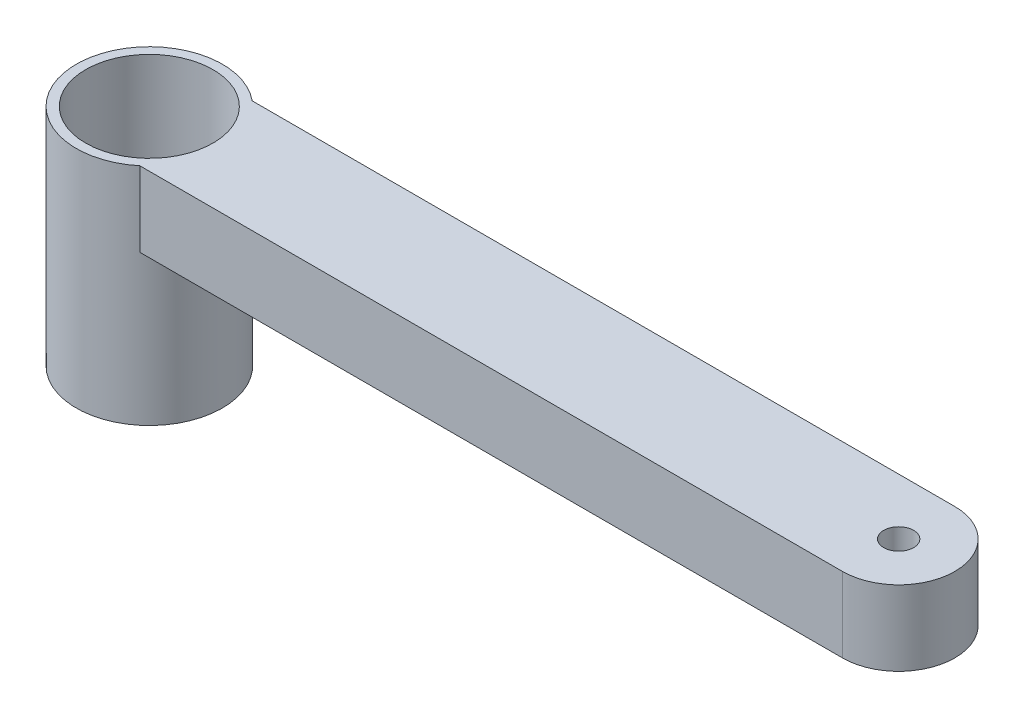
from build123d import *

# Parameters (mm, degrees)
SKETCH2_R           = 2.5
SKETCH2_R_2         = 2
BOSS_EXTRUDE1_DEPTH = 10
SKETCH3_R           = 9.75
BOSS_EXTRUDE2_DEPTH = 30
CUT_EXTRUDE1_REACH  = 32
SKETCH4_R           = 8.5


with BuildPart() as part:
    # Sketch2 → Boss-Extrude1 (new body)
    with BuildSketch(Plane(origin=(0, 0, 0), x_dir=(1, 0, 0), z_dir=(0, 1, 0))):
        with BuildLine():
            Line((0, 7.5), (100, 7.5))
            ThreePointArc((100, 7.5), (107.5, 0), (100, -7.5))
            Line((100, -7.5), (0, -7.5))
            ThreePointArc((0, -7.5), (-7.5, 0), (0, 7.5))
        make_face()
        Circle(SKETCH2_R, mode=Mode.SUBTRACT)
        with Locations((100, 0)):
            Circle(SKETCH2_R_2, mode=Mode.SUBTRACT)
    extrude(amount=BOSS_EXTRUDE1_DEPTH)

    # Sketch3 → Boss-Extrude2 (add)
    with BuildSketch(Plane(origin=(0, 10, 0), x_dir=(-1, 0, 0), z_dir=(0, -1, 0))):
        Circle(SKETCH3_R)
    extrude(amount=BOSS_EXTRUDE2_DEPTH)

    # Sketch4 → Cut-Extrude1 (cut, up to next)
    with BuildSketch(Plane(origin=(0, 10, 0), x_dir=(1, 0, 0), z_dir=(0, 1, 0)), mode=Mode.PRIVATE) as cut_extrude1_sk1:
        Circle(SKETCH4_R)
    cut_extrude1_tool1 = extrude(cut_extrude1_sk1.sketch, amount=-CUT_EXTRUDE1_REACH, mode=Mode.PRIVATE) & part.part
    add(cut_extrude1_tool1.solids().sort_by_distance((0, 10, 0))[0], mode=Mode.SUBTRACT)


solid = part.part
